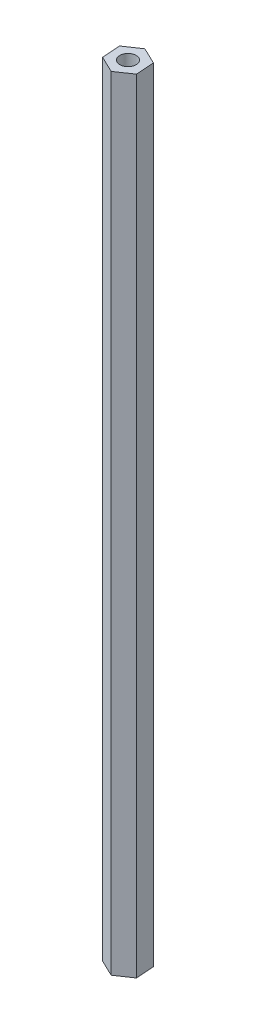
from build123d import *

# Parameters (mm, degrees)
BOSS_EXTRUDE1_DEPTH = 157.099
SKETCH2_R           = 3.2639
CUT_EXTRUDE1_DEPTH  = 12.7


with BuildPart() as part:
    # Sketch1 → Boss-Extrude1 (new body, symmetric)
    with BuildSketch(Plane(origin=(0, 0, 0), x_dir=(1, 0, 0), z_dir=(0, 1, 0))):
        Polygon((6.05685162, 4.132539387), (-0.550458281, 7.311657064), (-6.607309901, 3.179117677), (-6.05685162, -4.132539387), (0.550458281, -7.311657064), (6.607309901, -3.179117677), align=None)
    extrude(amount=BOSS_EXTRUDE1_DEPTH, both=True)

    # Sketch2 → Cut-Extrude1 (cut)
    with BuildSketch(Plane(origin=(0, 157.099, 0), x_dir=(1, 0, 0), z_dir=(0, 1, 0))):
        Circle(SKETCH2_R)
    cut_extrude1 = extrude(amount=-CUT_EXTRUDE1_DEPTH, mode=Mode.SUBTRACT)

    # Mirror1: Cut-Extrude1 across plane
    add(cut_extrude1.mirror(Plane.ZX), mode=Mode.SUBTRACT)


solid = part.part
